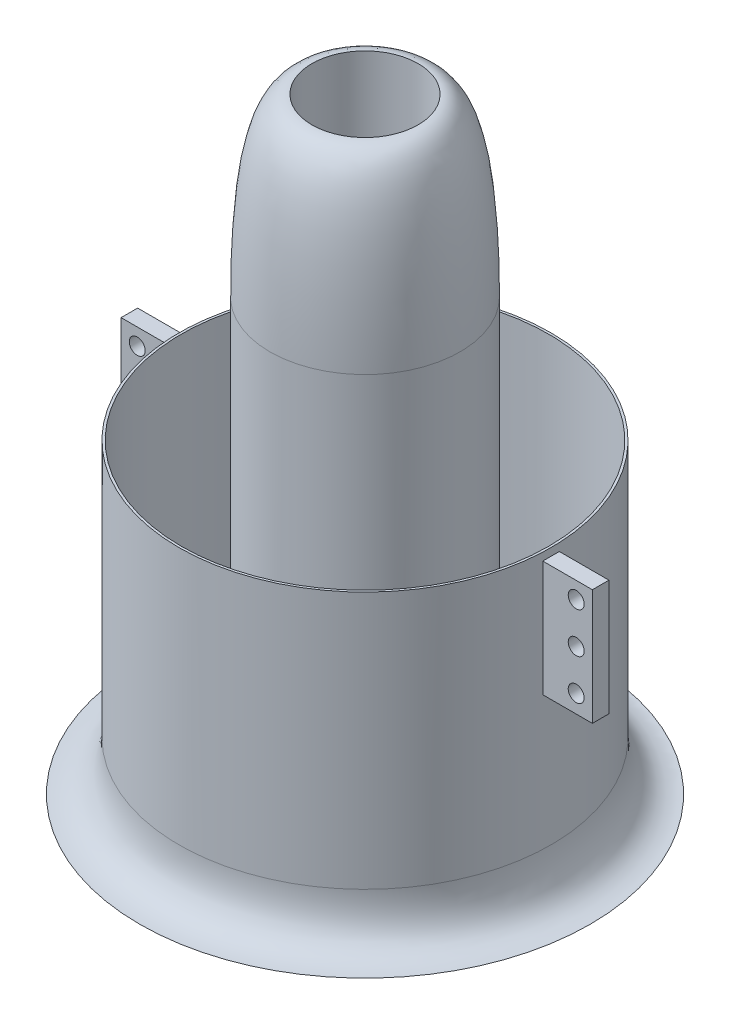
from build123d import *

# Parameters (mm, degrees)
SKETCH_1_R          = 45
EXTRUDE_1_DEPTH     = 29.82
SKETCH_2_W          = 12
SKETCH_2_H          = 28
SKETCH_2_R          = 1.93
EXTRUDE_2_DEPTH     = 2
EXTRUDE_2_2_DEPTH   = 2
SKETCH_3_R          = 21.35
EXTRUDE_3_DEPTH     = 25.7
SKETCH_4_R          = 7.41
EXTRUDE_4_DEPTH     = 7
SKETCH_5_R          = 45
EXTRUDE_5_DEPTH     = 32.46
SKETCH_7_R          = 23
EXTRUDE_6_DEPTH     = 30
SKETCH_11_R         = 44.450781265
SKETCH_11_R_2       = 23
CUT_EXTRUDE_1_DEPTH = 118.34
EXTRUDE_7_DEPTH     = 5


with BuildPart() as part:
    # 草图1 → 凸台-拉伸1 (new body)
    with BuildSketch(Plane(origin=(0, 0, 0), x_dir=(1, 0, 0), z_dir=(0, 1, 0))):
        Circle(SKETCH_1_R)
    extrude(amount=EXTRUDE_1_DEPTH)

    # 草图3 → 凸台-拉伸3 (add)
    with BuildSketch(Plane(origin=(0, 29.82, 0), x_dir=(1, 0, 0), z_dir=(0, 1, 0))):
        Circle(SKETCH_3_R)
    extrude(amount=EXTRUDE_3_DEPTH)

    # 草图4 → 凸台-拉伸4 (add)
    with BuildSketch(Plane(origin=(0, 55.52, 0), x_dir=(1, 0, 0), z_dir=(0, 1, 0))):
        Circle(SKETCH_4_R)
    extrude(amount=EXTRUDE_4_DEPTH)

    # 草图5 → 凸台-拉伸5 (add)
    with BuildSketch(Plane.XZ):
        Circle(SKETCH_5_R)
    extrude(amount=EXTRUDE_5_DEPTH)

    # 草图6 → 旋转1 (revolve)
    with BuildSketch(Plane.XY):
        with BuildLine():
            Line((-54.5, -44.34), (0, -44.34))
            Line((0, -44.34), (0, -32.46))
            Line((0, -32.46), (-45, -32.46))
            add(Edge.make_bspline(
                [(-45, -32.46), (-45, -44.34), (-54.5, -44.34)],
                knots=[0, 0, 0, 1, 1, 1], degree=2))
        make_face()
    revolve(axis=Axis((0, -44.34, 0), (0, 1, 0)))

    # 草图7 → 凸台-拉伸6 (add)
    with BuildSketch(Plane(origin=(0, 29.82, 0), x_dir=(1, 0, 0), z_dir=(0, 1, 0))):
        Circle(SKETCH_7_R)
    extrude(amount=EXTRUDE_6_DEPTH)

    # 草图8 → 旋转2 (revolve)
    with BuildSketch(Plane.XY):
        with BuildLine():
            Line((12.85, 102.3), (12.85, 59.82))
            Line((12.85, 59.82), (23, 59.82))
            add(Edge.make_bspline(
                [(12.85, 102.3), (23, 102.3), (23, 59.82)],
                knots=[0, 0, 0, 1, 1, 1], degree=2))
        make_face()
    revolve(axis=Axis((0, 59.82, 0), (0, 1, 0)))

    # 草图10 → 旋转3 (revolve)
    with BuildSketch(Plane.XY):
        with BuildLine():
            Line((0, -72.34), (0, -44.34))
            Line((0, -44.34), (12.85, -44.34))
            add(Edge.make_bspline(
                [(12.85, -44.34), (6.425, -72.34), (0, -72.34)],
                knots=[0, 0, 0, 1, 1, 1], degree=2))
        make_face()
    revolve(axis=Axis((0, -72.34, 0), (0, 1, 0)))

    # 草图11 → 切除-拉伸1 (cut)
    with BuildSketch(Plane.XZ.offset(44.34)):
        Circle(SKETCH_11_R)
        Circle(SKETCH_11_R_2, mode=Mode.SUBTRACT)
    extrude(amount=-CUT_EXTRUDE_1_DEPTH, mode=Mode.SUBTRACT)

    # 草图12 → 凸台-拉伸7 (add)
    with BuildSketch(Plane.XZ.offset(44.34)):
        with BuildLine():
            Line((2, 33.725390633), (2, 44.405764886))
            ThreePointArc((2, 44.405764886), (0, 44.450781265), (-2, 44.405764886))
            Line((-2, 44.405764886), (-2, 33.725390633))
            Line((-2, 33.725390633), (-2, 22.912878475))
            Line((-2, 22.912878475), (2, 22.912878475))
            Line((2, 22.912878475), (2, 33.725390633))
        make_face()
        with BuildLine():
            Line((21.173408392, 8.982581871), (22.409476369, 5.178355806))
            Line((22.409476369, 5.178355806), (32.692786515, 8.519605815))
            Line((32.692786515, 8.519605815), (42.850426045, 11.820022965))
            ThreePointArc((42.850426045, 11.820022965), (42.275205177, 13.736046824), (41.614358067, 15.624249031))
            Line((41.614358067, 15.624249031), (31.456718537, 12.32383188))
            Line((31.456718537, 12.32383188), (21.173408392, 8.982581871))
        make_face()
        with BuildLine():
            Line((15.085886044, -17.361337572), (11.849818066, -19.712478581))
            Line((11.849818066, -19.712478581), (18.205253253, -28.459984668))
            Line((18.205253253, -28.459984668), (24.483019728, -37.100588946))
            ThreePointArc((24.483019728, -37.100588946), (26.127513681, -35.961437457), (27.719087706, -34.749447936))
            Line((27.719087706, -34.749447936), (21.44132123, -26.108843659))
            Line((21.44132123, -26.108843659), (15.085886044, -17.361337572))
        make_face()
        with BuildLine():
            Line((-11.849818066, -19.712478581), (-15.085886044, -17.361337572))
            Line((-15.085886044, -17.361337572), (-21.44132123, -26.108843659))
            Line((-21.44132123, -26.108843659), (-27.719087706, -34.749447936))
            ThreePointArc((-27.719087706, -34.749447936), (-26.127513681, -35.961437457), (-24.483019728, -37.100588946))
            Line((-24.483019728, -37.100588946), (-18.205253253, -28.459984668))
            Line((-18.205253253, -28.459984668), (-11.849818066, -19.712478581))
        make_face()
        with BuildLine():
            Line((-22.409476369, 5.178355806), (-21.173408392, 8.982581871))
            Line((-21.173408392, 8.982581871), (-31.456718537, 12.32383188))
            Line((-31.456718537, 12.32383188), (-41.614358067, 15.624249031))
            ThreePointArc((-41.614358067, 15.624249031), (-42.275205177, 13.736046824), (-42.850426045, 11.820022965))
            Line((-42.850426045, 11.820022965), (-32.692786515, 8.519605815))
            Line((-32.692786515, 8.519605815), (-22.409476369, 5.178355806))
        make_face()
    extrude(amount=-EXTRUDE_7_DEPTH)


with BuildPart() as body_2:
    # 草图2 → 凸台-拉伸2 (new body, symmetric)
    with BuildSketch(Plane.XY):
        with Locations((51, 14)):
            Rectangle(SKETCH_2_W, SKETCH_2_H)
        with Locations((53.09, 23.97)):
            Circle(SKETCH_2_R, mode=Mode.SUBTRACT)
        with Locations((53.09, 14.145)):
            Circle(SKETCH_2_R, mode=Mode.SUBTRACT)
        with Locations((53.09, 4.33)):
            Circle(SKETCH_2_R, mode=Mode.SUBTRACT)
    extrude(amount=EXTRUDE_2_DEPTH, both=True)


with BuildPart() as body_3:
    # 草图2 → Extrude 2 2 (new body, symmetric)
    with BuildSketch(Plane.XY):
        with Locations((-51, 14)):
            Rectangle(SKETCH_2_W, SKETCH_2_H)
        with Locations((-53.09, 4.33)):
            Circle(SKETCH_2_R, mode=Mode.SUBTRACT)
        with Locations((-53.09, 14.145)):
            Circle(SKETCH_2_R, mode=Mode.SUBTRACT)
        with Locations((-53.09, 23.97)):
            Circle(SKETCH_2_R, mode=Mode.SUBTRACT)
    extrude(amount=EXTRUDE_2_2_DEPTH, both=True)


solid = Compound([part.part, body_2.part, body_3.part])
